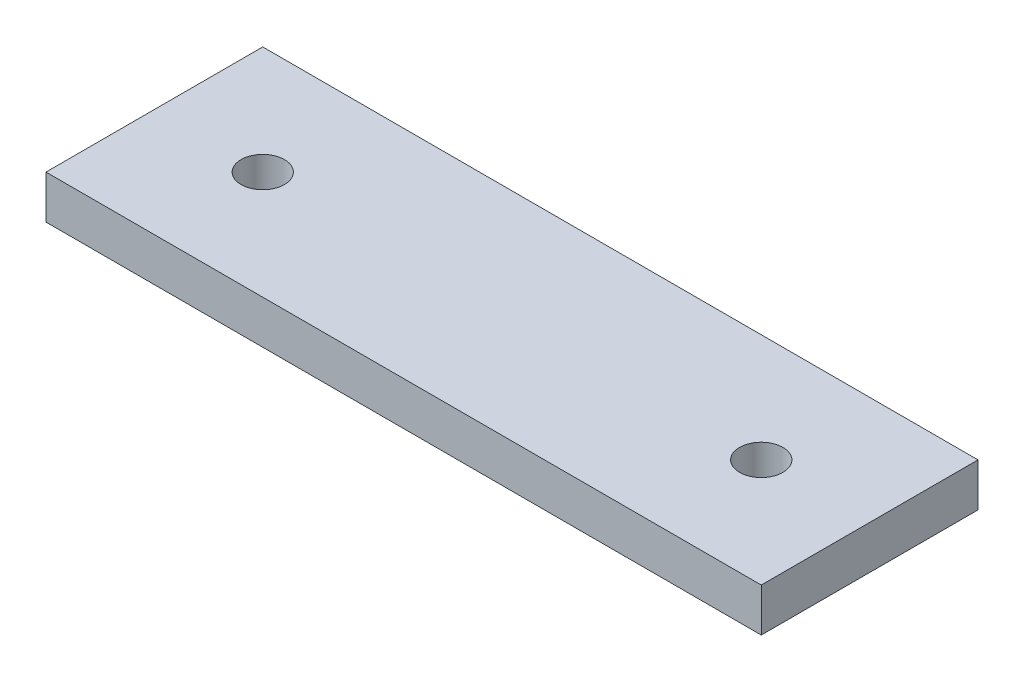
from build123d import *

# Parameters (mm, degrees)
SKETCH1_W           = 66
SKETCH1_H           = 20
BOSS_EXTRUDE1_DEPTH = 4
SKETCH2_R           = 2
CUT_EXTRUDE1_DEPTH  = 5


with BuildPart() as part:
    # Sketch1 → Boss-Extrude1 (new body)
    with BuildSketch(Plane(origin=(0, 0, 0), x_dir=(1, 0, 0), z_dir=(0, 1, 0))):
        with Locations((33, -10)):
            Rectangle(SKETCH1_W, SKETCH1_H)
    extrude(amount=BOSS_EXTRUDE1_DEPTH)

    # Sketch2 → Cut-Extrude1 (cut, through all)
    with BuildSketch(Plane(origin=(0, 4, 0), x_dir=(1, 0, 0), z_dir=(0, 1, 0))):
        with Locations((10, -10)):
            Circle(SKETCH2_R)
        with Locations((56, -10)):
            Circle(SKETCH2_R)
    extrude(amount=-CUT_EXTRUDE1_DEPTH, mode=Mode.SUBTRACT)


solid = part.part
